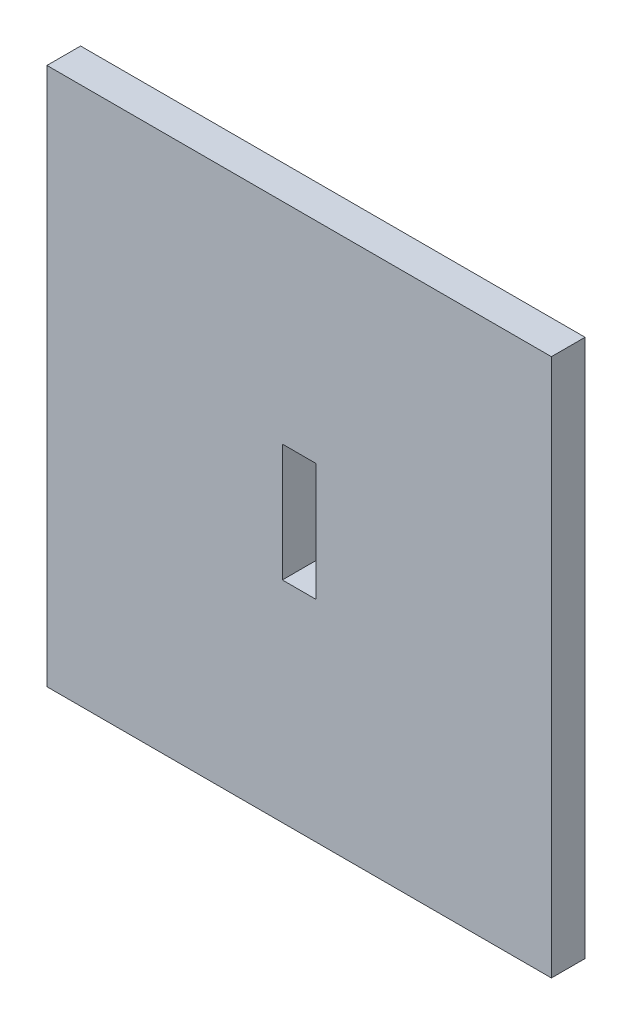
from build123d import *

# Parameters (mm, degrees)
SKETCH1_W           = 30
SKETCH1_H           = 32
SKETCH1_W_2         = 2
SKETCH1_H_2         = 7
BOSS_EXTRUDE1_DEPTH = 2


with BuildPart() as part:
    # Sketch1 → Boss-Extrude1 (new body)
    with BuildSketch(Plane.XY):
        Rectangle(SKETCH1_W, SKETCH1_H)
        Rectangle(SKETCH1_W_2, SKETCH1_H_2, mode=Mode.SUBTRACT)
    extrude(amount=BOSS_EXTRUDE1_DEPTH)


solid = part.part
